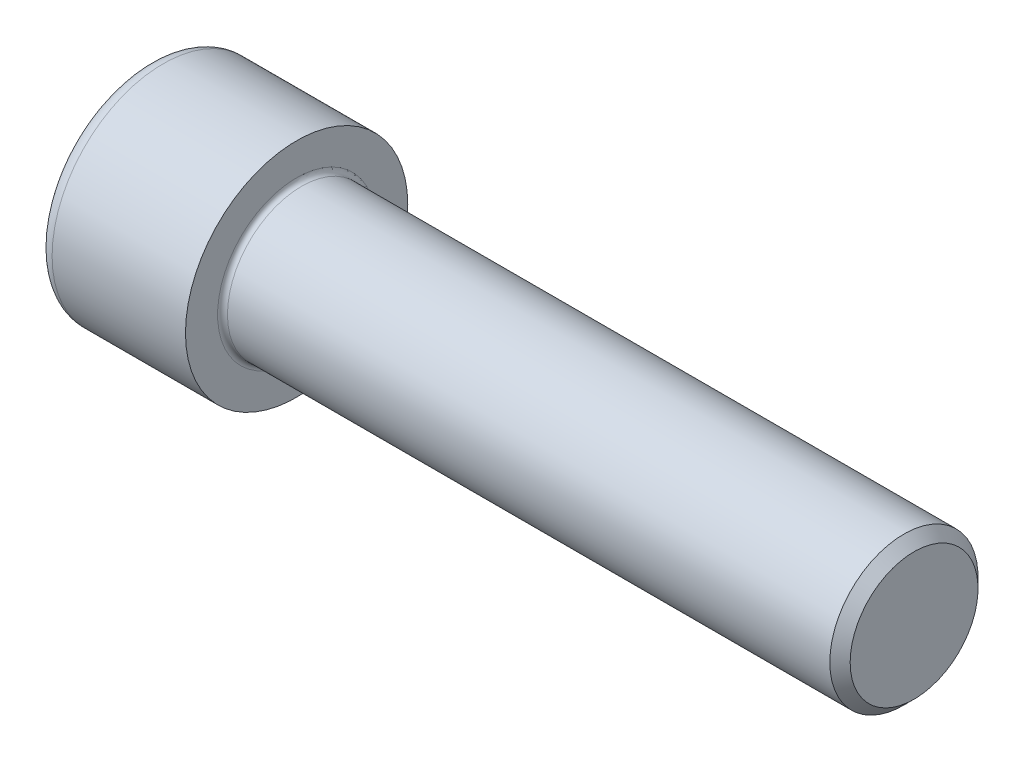
from build123d import *

# Parameters (mm, degrees)
BASEHEADSKE_R   = 18
BASEHEAD_DEPTH  = 24
CUTSOCKET_DEPTH = 12
FILLET1_R       = 0.8
FILLET2_R       = 2.4


with BuildPart() as part:
    # BaseHeadSke → BaseHead (new body)
    with BuildSketch(Plane(origin=(0, 0, 0), x_dir=(0, 0, -1), z_dir=(1, 0, 0))):
        Circle(BASEHEADSKE_R)
    extrude(amount=BASEHEAD_DEPTH)

    # BodySke → BaseBody (revolve)
    with BuildSketch(Plane.XY):
        Polygon((0, 0), (124, 0), (124, 10.352), (122.352, 12), (0, 12), align=None)
    revolve(axis=Axis((0, 0, 0), (1, 0, 0)))

    # CutSocketSke → CutSocket (cut)
    with BuildSketch(Plane(origin=(0, 0, 0), x_dir=(0, 0, -1), z_dir=(1, 0, 0))):
        Polygon((0, 10.969655115), (-9.5, 5.484827557), (-9.5, -5.484827557), (0, -10.969655115), (9.5, -5.484827557), (9.5, 5.484827557), align=None)
    extrude(amount=CUTSOCKET_DEPTH, mode=Mode.SUBTRACT)

    # CutHoleSke → CutHole (revolve, cut)
    with BuildSketch(Plane.XY):
        Polygon((0, 9.5), (13.6, 9.5), (19.084827557, 0), (0, 0), align=None)
    revolve(axis=Axis((0, 0, 0), (1, 0, 0)), mode=Mode.SUBTRACT)

    # Fillet1
    fillet1_edges = [part.edges().sort_by_distance(p)[0] for p in [
        (24, -12, 0),
    ]]
    fillet(fillet1_edges, radius=FILLET1_R)

    # Fillet2
    fillet2_edges = [part.edges().sort_by_distance(p)[0] for p in [
        (0, 0, 18),
    ]]
    fillet(fillet2_edges, radius=FILLET2_R)


solid = part.part
